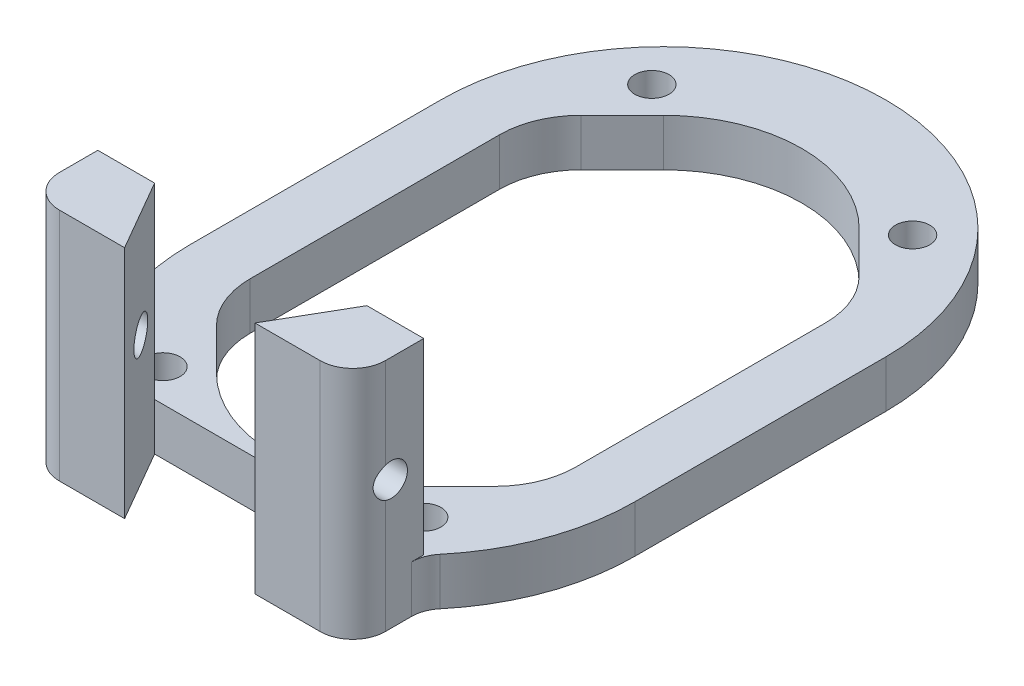
from build123d import *

# Parameters (mm, degrees)
BOSS_EXTRUDE6_DEPTH      = 2.9
SKETCH27_R               = 1.05
CUT_EXTRUDE12_DEPTH      = 3.9
SKETCH29_W               = 20
SKETCH29_H               = 4.356134153
BOSS_EXTRUDE8_DEPTH      = 11.5
BOSS_EXTRUDE8_DEPTH_BACK = 2.9
CUT_EXTRUDE13_DEPTH      = 15.4
FILLET1_R                = 2
SKETCH31_R               = 1
CUT_EXTRUDE14_DEPTH      = 4.656134153
CUT_EXTRUDE14_DEPTH_BACK = 24.656134153
CUT_EXTRUDE16_DEPTH      = 10
FILLET3_R                = 5
FILLET3_OF_MIRROR2_R     = 5


with BuildPart() as part:
    # Sketch26 → Boss-Extrude6 (new body)
    with BuildSketch(Plane(origin=(0, 0, 0), x_dir=(1, 0, 0), z_dir=(0, 1, 0))):
        with BuildLine():
            Line((-13.656134153, -7.7), (-13.656134153, 7.7))
            ThreePointArc((-13.656134153, 7.7), (0, 21.356134153), (13.656134153, 7.7))
            Line((13.656134153, 7.7), (13.656134153, -7.7))
            ThreePointArc((13.656134153, -7.7), (0, -21.356134153), (-13.656134153, -7.7))
        make_face()
        with BuildLine():
            Line((-8.5, 7.7), (-8.5, -7.7))
            ThreePointArc((-8.5, -7.7), (0, -16.2), (8.5, -7.7))
            Line((8.5, -7.7), (8.5, 7.7))
            ThreePointArc((8.5, 7.7), (0, 16.2), (-8.5, 7.7))
        make_face(mode=Mode.SUBTRACT)
    extrude(amount=BOSS_EXTRUDE6_DEPTH)

    # Sketch27 → Cut-Extrude12 (cut, through all)
    with BuildSketch(Plane(origin=(0, 2.9, 0), x_dir=(1, 0, 0), z_dir=(0, 1, 0))):
        with Locations((-8, 15)):
            Circle(SKETCH27_R)
        with Locations((8, 15)):
            Circle(SKETCH27_R)
        with Locations((8, -15)):
            Circle(SKETCH27_R)
        with Locations((-8, -15)):
            Circle(SKETCH27_R)
    extrude(amount=-CUT_EXTRUDE12_DEPTH, mode=Mode.SUBTRACT)

    # Sketch29 → Boss-Extrude8 (add, two sides)
    with BuildSketch(Plane(origin=(0, 2.9, 0), x_dir=(1, 0, 0), z_dir=(0, 1, 0))) as boss_extrude8_sk:
        with Locations((0, -19.178067076)):
            Rectangle(SKETCH29_W, SKETCH29_H)
    extrude(amount=BOSS_EXTRUDE8_DEPTH)
    extrude(boss_extrude8_sk.sketch, amount=-BOSS_EXTRUDE8_DEPTH_BACK)

    # Sketch30 → Cut-Extrude13 (cut, through all)
    with BuildSketch(Plane(origin=(0, 14.4, 0), x_dir=(1, 0, 0), z_dir=(0, 1, 0))):
        Polygon((-4, -21.356134153), (-6.515015226, -17), (6.515015226, -17), (4, -21.356134153), align=None)
    extrude(amount=-CUT_EXTRUDE13_DEPTH, mode=Mode.SUBTRACT)

    # Fillet1
    fillet1_edges = [part.edges().sort_by_distance(p)[0] for p in [
        (10, 7.2, 21.356134153),
        (10, 1.45, 17),
        (-10, 1.45, 17),
        (-10, 7.2, 21.356134153),
    ]]
    fillet(fillet1_edges, radius=FILLET1_R)

    # Sketch31 → Cut-Extrude14 (cut, two sides)
    with BuildSketch(Plane.ZY.offset(10)) as cut_extrude14_sk:
        with Locations((19, 7.9)):
            Circle(SKETCH31_R)
    extrude(amount=CUT_EXTRUDE14_DEPTH, mode=Mode.SUBTRACT)
    extrude(cut_extrude14_sk.sketch, amount=-CUT_EXTRUDE14_DEPTH_BACK, mode=Mode.SUBTRACT)

    # Sketch34 → Cut-Extrude16 (cut)
    with BuildSketch(Plane(origin=(0, 2.9, 0), x_dir=(1, 0, 0), z_dir=(0, 1, 0))):
        Polygon((-10, 9.72081528), (-6.01040764, 13.71040764), (-6.01040764, -13.71040764), (-10, -9.72081528), align=None)
    cut_extrude16 = extrude(amount=-CUT_EXTRUDE16_DEPTH, mode=Mode.SUBTRACT)

    # Fillet3
    fillet3_edges = [part.edges().sort_by_distance(p)[0] for p in [
        (-10, 1.45, 9.72081528),
        (-10, 1.45, -9.72081528),
    ]]
    fillet(fillet3_edges, radius=FILLET3_R)

    # Mirror2: Cut-Extrude16 across plane
    add(cut_extrude16.mirror(Plane(origin=(0, 0, 0), x_dir=(0, 0, 1), z_dir=(1, 0, 0))), mode=Mode.SUBTRACT)

    # Fillet3 of Mirror2
    fillet3_of_mirror2_edges = [part.edges().sort_by_distance(p)[0] for p in [
        (10, 1.45, 9.72081528),
        (10, 1.45, -9.72081528),
    ]]
    fillet(fillet3_of_mirror2_edges, radius=FILLET3_OF_MIRROR2_R)


solid = part.part
